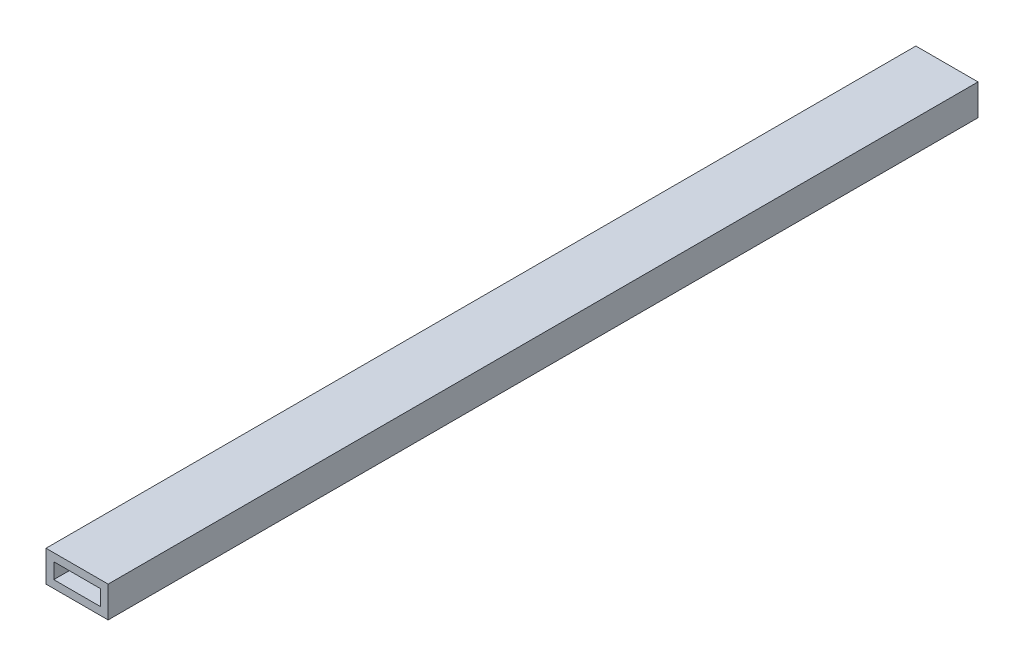
from build123d import *

# Parameters (mm, degrees)
SKETCH1_W           = 25.4
SKETCH1_H           = 12.7
SKETCH1_W_2         = 19.05
SKETCH1_H_2         = 6.35
BOSS_EXTRUDE1_DEPTH = 355.6


with BuildPart() as part:
    # Sketch1 → Boss-Extrude1 (new body)
    with BuildSketch(Plane.XY):
        with Locations((12.7, 6.35)):
            Rectangle(SKETCH1_W, SKETCH1_H)
        with Locations((12.7, 6.35)):
            Rectangle(SKETCH1_W_2, SKETCH1_H_2, mode=Mode.SUBTRACT)
    extrude(amount=BOSS_EXTRUDE1_DEPTH)


solid = part.part
